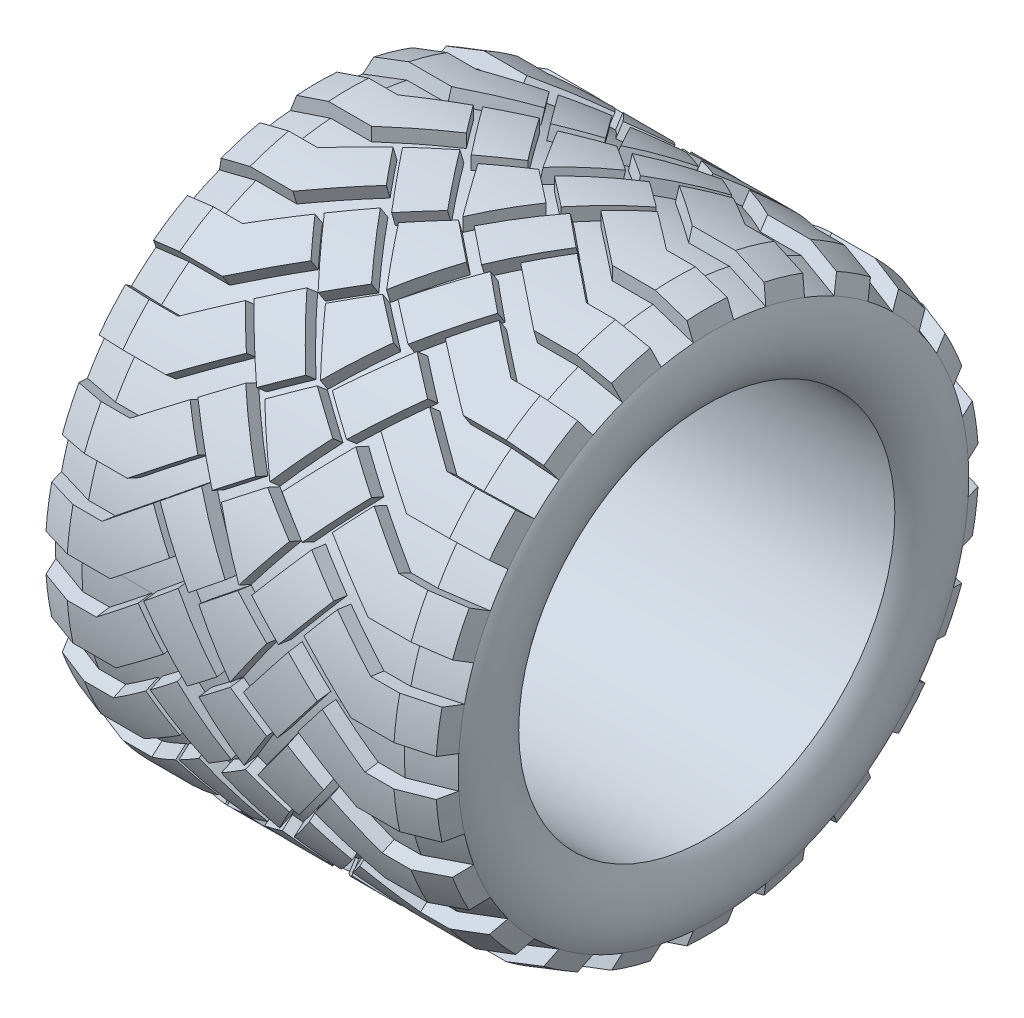
from build123d import *

# Parameters (mm, degrees)
BOSS_EXTRUDE1_DEPTH = 2.5
CIRPATTERN1_COUNT   = 22


with BuildPart() as part:
    # Sketch1 → Revolve1 (revolve)
    with BuildSketch(Plane(origin=(0, 0, 0), x_dir=(1, 0, 0), z_dir=(0, 1, 0))):
        with BuildLine():
            Line((-12, 20), (12, 20))
            Line((12, 20), (15, 19))
            ThreePointArc((15, 19), (15.526708933, 16.422329107), (14.5, 14))
            Line((14.5, 14), (-14.5, 14))
            ThreePointArc((-14.5, 14), (-15.526708933, 16.422329107), (-15, 19))
            Line((-15, 19), (-12, 20))
        make_face()
    revolve(axis=Axis((-25, 0, 0), (1, 0, 0)))

    # Sketch2 → Boss-Extrude1 (add, symmetric)
    with BuildSketch(Plane(origin=(0, 20, 0), x_dir=(1, 0, 0), z_dir=(0, 1, 0))):
        Polygon((-15, 1.5), (-15, -1.5), (-8.963320559, -1.5), (-5.001201865, 1.609623007), (-6.853388237, 3.969581829), (-10, 1.5), align=None)
        Polygon((5.001201865, 1.609623007), (8.963320559, -1.5), (15, -1.5), (15, 1.5), (10, 1.5), (6.853388237, 3.969581829), align=None)
        Polygon((-6.460061766, 4.278279558), (-3.348462392, 0.31364268), (-0.988503569, 2.165829052), (-4.100102944, 6.13046593), align=None)
        Polygon((0.988503569, 2.165829052), (4.100102944, 6.13046593), (6.460061766, 4.278279558), (3.348462392, 0.31364268), align=None)
        Polygon((-2.533308899, 0), (0, 1.988238173), (2.533308899, 0), (0, -3.660725479), align=None)
    boss_extrude1 = extrude(amount=BOSS_EXTRUDE1_DEPTH, both=True)

    # CirPattern1: Boss-Extrude1 ×22 about axis
    cirpattern1_axis = Axis((0, 0, 0), (1, 0, 0))
    for i in range(1, CIRPATTERN1_COUNT):
        add(boss_extrude1.rotate(cirpattern1_axis, i * 360 / CIRPATTERN1_COUNT))

    # Sketch4 → Cut-Revolve1 (revolve, cut)
    with BuildSketch(Plane(origin=(0, 0, 0), x_dir=(1, 0, 0), z_dir=(0, 1, 0))):
        Polygon((-15.316227766, 19.948683298), (-15.316227766, 32.896909244), (15.316227766, 32.896909244), (15.316227766, 19.948683298), (15, 19), (14.52654113, 20.211912177), (12.16227766, 21), (-12.16227766, 21), (-14.52654113, 20.211912177), (-15, 19), align=None)
    revolve(axis=Axis((-15, 0, 0), (1, 0, 0)), mode=Mode.SUBTRACT)


solid = part.part
